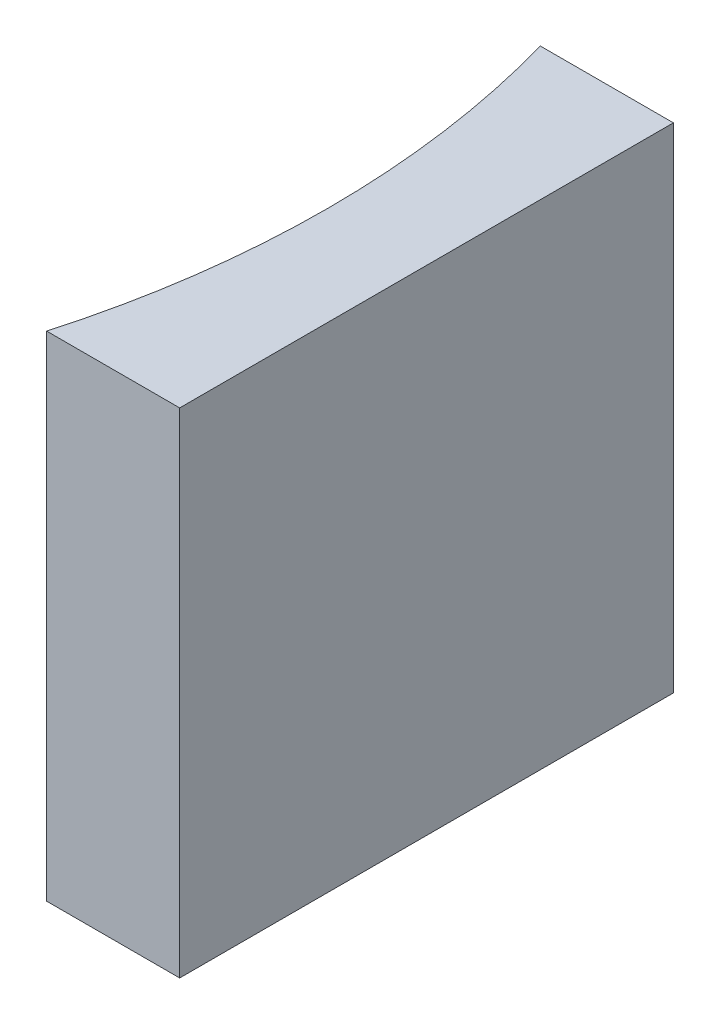
from build123d import *

# Parameters (mm, degrees)
EXTRUDE_1_DEPTH = 10


with BuildPart() as part:
    # 草图1 → 凸台-拉伸1 (new body)
    with BuildSketch(Plane(origin=(0, 0, 0), x_dir=(1, 0, 0), z_dir=(0, 1, 0))):
        with BuildLine():
            Line((0, 0), (0, -10))
            Line((0, -10), (-2.695517029, -10))
            ThreePointArc((-2.695517029, -10), (-2, -5), (-2.695517029, 0))
            Line((-2.695517029, 0), (0, 0))
        make_face()
    extrude(amount=EXTRUDE_1_DEPTH)


solid = part.part
